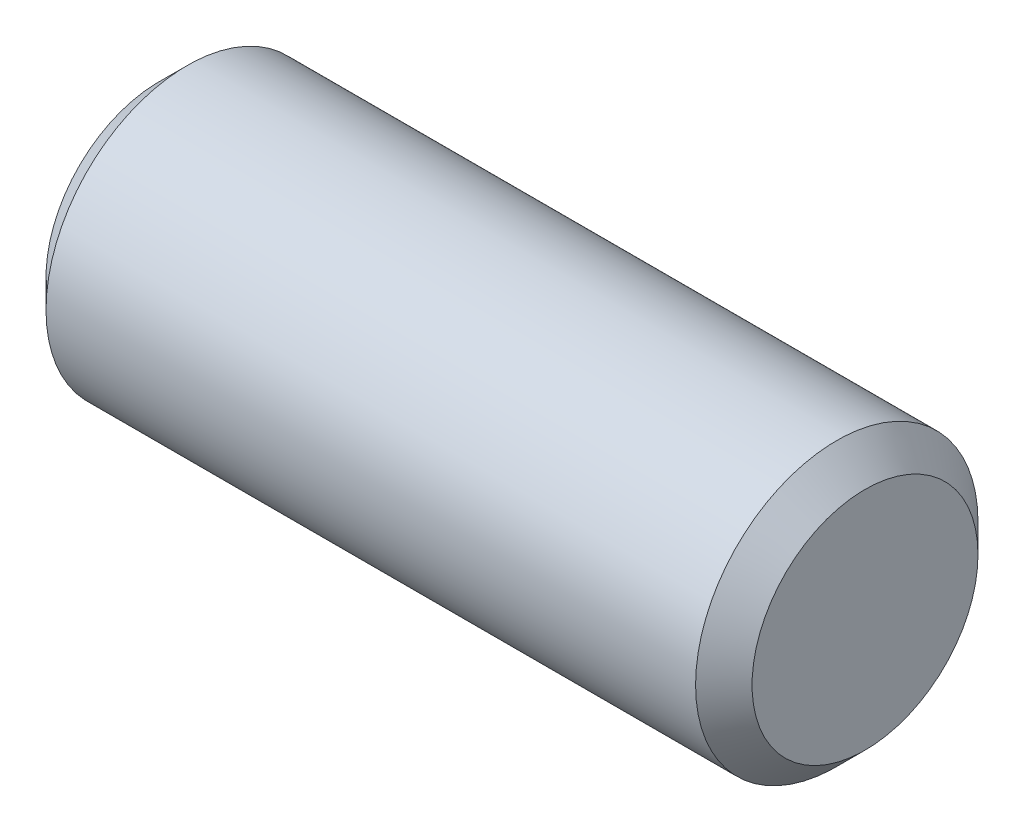
from build123d import *

# Parameters (mm, degrees)
SKETCH2_R           = 3.175
EXTRUDE1_DEPTH      = 7.9375
EXTRUDE1_DEPTH_BACK = 7.9375
CHAMFER1_SIZE       = 0.635


with BuildPart() as part:
    # Sketch2 → Extrude1 (new body, two sides)
    with BuildSketch(Plane(origin=(0, 0, 0), x_dir=(0, 0, -1), z_dir=(1, 0, 0))) as extrude1_sk:
        Circle(SKETCH2_R)
    extrude(amount=EXTRUDE1_DEPTH)
    extrude(extrude1_sk.sketch, amount=-EXTRUDE1_DEPTH_BACK)

    # Chamfer1
    chamfer1_edges = [part.edges().sort_by_distance(p)[0] for p in [
        (-7.9375, 0, 3.175),
        (7.9375, 0, 3.175),
    ]]
    chamfer(chamfer1_edges, length=CHAMFER1_SIZE)


solid = part.part
